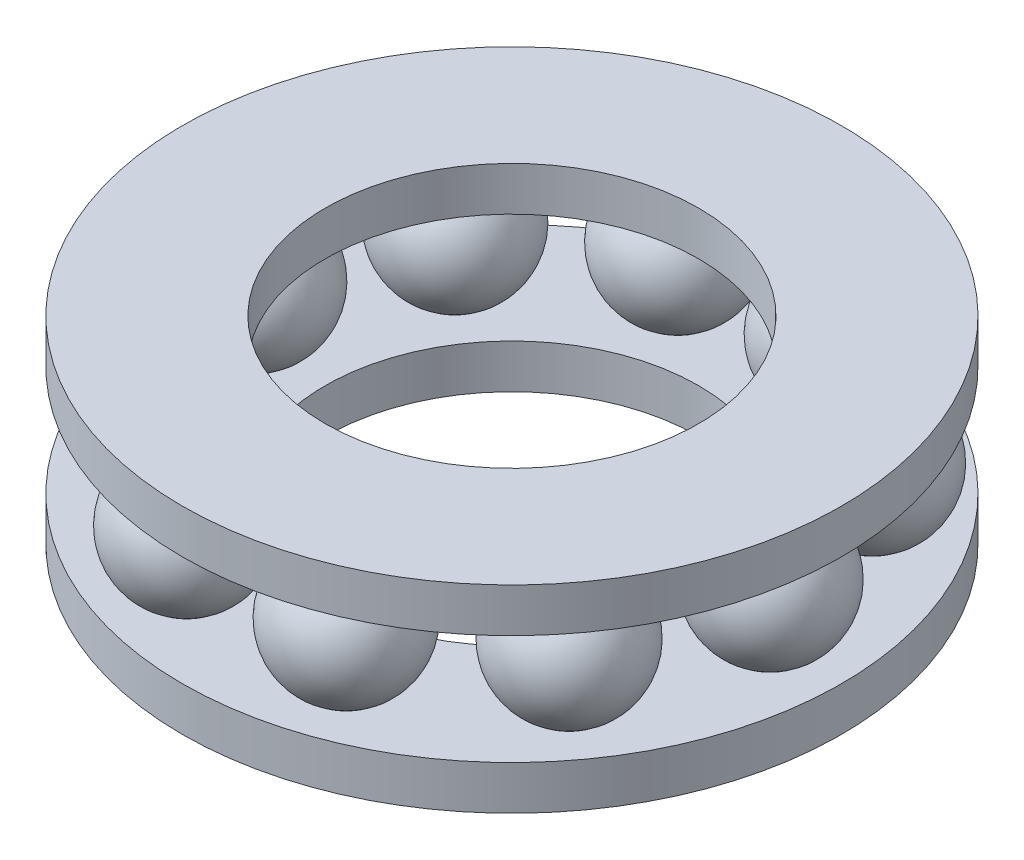
from build123d import *

# Parameters (mm, degrees)
SKETCH_1_R               = 15
SKETCH_1_R_2             = 8.5
EXTRUDE_1_DEPTH          = 2
PATTERN_CIRCULAR_2_COUNT = 10
PATTERN_LINEAR_2_COUNT   = 2
PATTERN_LINEAR_2_PITCH   = 7


with BuildPart() as part:
    # 草图1 → 凸台-拉伸1 (new body)
    with BuildSketch(Plane(origin=(0, 0, 0), x_dir=(1, 0, 0), z_dir=(0, 1, 0))):
        Circle(SKETCH_1_R)
        Circle(SKETCH_1_R_2, mode=Mode.SUBTRACT)
    extrude_1 = extrude(amount=EXTRUDE_1_DEPTH)

    # 草图4 → 旋转4 (revolve)
    with BuildSketch(Plane.XY):
        with BuildLine():
            Line((8.75, 4.5), (14.75, 4.5))
            ThreePointArc((14.75, 4.5), (11.75, 1.5), (8.75, 4.5))
        make_face()
    revolve_4 = revolve(axis=Axis((8.75, 4.5, 0), (1, 0, 0)))

    # 阵列(圆周)2: 旋转4 ×10 about axis
    pattern_circular_2_axis = Axis((0, 0, 0), (0, 1, 0))
    for i in range(1, PATTERN_CIRCULAR_2_COUNT):
        add(revolve_4.rotate(pattern_circular_2_axis, i * 360 / PATTERN_CIRCULAR_2_COUNT))

    # 阵列(线性)2: 凸台-拉伸1 ×2
    with Locations(*[(0, i * PATTERN_LINEAR_2_PITCH, 0) for i in range(1, PATTERN_LINEAR_2_COUNT)]):
        add(extrude_1)


solid = part.part
